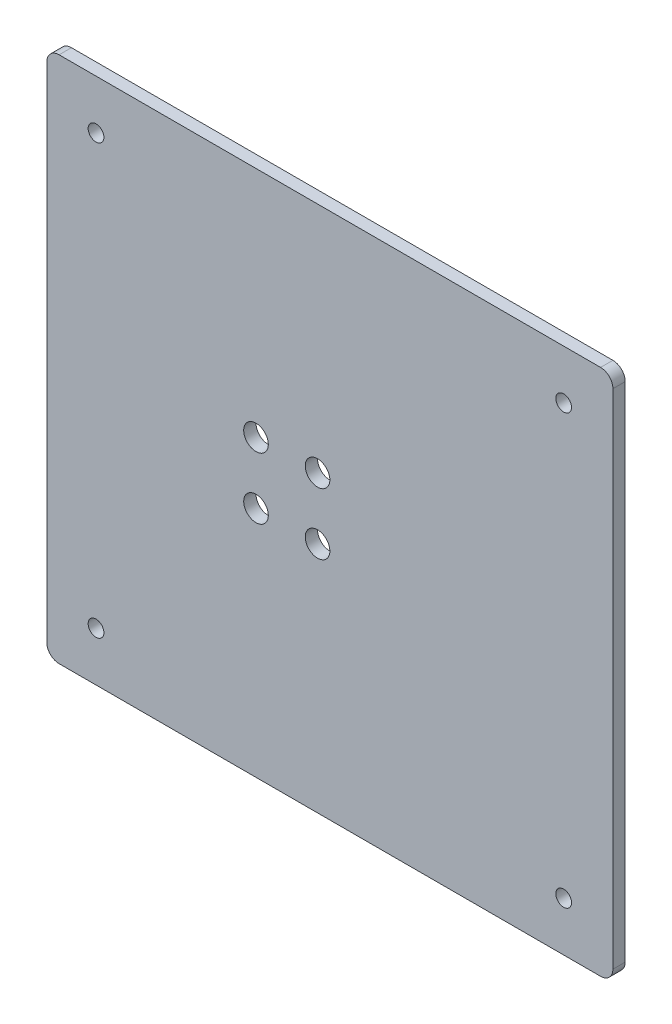
from build123d import *

# Parameters (mm, degrees)
SKETCH_1_W                  = 170
SKETCH_1_H                  = 154.25
SKETCH_1_W_2                = 160
SKETCH_1_H_2                = 144.25
EXTRUDE_1_DEPTH             = 8
FILLET_1_R                  = 5
SKETCH_2_W                  = 230
SKETCH_2_H                  = 214.25
EXTRUDE_2_DEPTH             = 5
FILLET_2_R                  = 5
HOLE_WIZARD_6_4_6_4_1_D     = 6.4
HOLE_WIZARD_6_4_6_4_1_DEPTH = 5
HOLE_WIZARD_10_0_10_1_D     = 10


with BuildPart() as part:
    # 草图1 → 凸台-拉伸1 (new body)
    with BuildSketch(Plane.XY):
        Rectangle(SKETCH_1_W, SKETCH_1_H)
        Rectangle(SKETCH_1_W_2, SKETCH_1_H_2, mode=Mode.SUBTRACT)
    extrude(amount=EXTRUDE_1_DEPTH)

    # 圆角1
    fillet_1_edges = [part.edges().sort_by_distance(p)[0] for p in [
        (-80, 72.125, 4),
        (-80, -72.125, 4),
        (80, -72.125, 4),
        (80, 72.125, 4),
        (-85, 77.125, 4),
        (85, 77.125, 4),
        (85, -77.125, 4),
        (-85, -77.125, 4),
    ]]
    fillet(fillet_1_edges, radius=FILLET_1_R)

    # 草图2 → 凸台-拉伸2 (add)
    with BuildSketch(Plane.XY.offset(8)):
        Rectangle(SKETCH_2_W, SKETCH_2_H)
    extrude(amount=EXTRUDE_2_DEPTH)

    # 圆角2
    fillet_2_edges = [part.edges().sort_by_distance(p)[0] for p in [
        (-115, 107.125, 10.5),
        (-115, -107.125, 10.5),
        (115, -107.125, 10.5),
        (115, 107.125, 10.5),
    ]]
    fillet(fillet_2_edges, radius=FILLET_2_R)

    # Ø6.4 (6.4) 直径孔1
    with Locations(Plane.XY.offset(13)):
        with Locations((-95, 87.125), (95, 87.125), (95, -87.125), (-95, -87.125)):
            Hole(HOLE_WIZARD_6_4_6_4_1_D / 2, depth=HOLE_WIZARD_6_4_6_4_1_DEPTH)

    # Ø10.0 (10) 直径孔1 (through all)
    with Locations(Plane.XY.offset(13)):
        with Locations((-30, 12.5), (-5, 12.5), (-5, -12.5), (-30, -12.5)):
            Hole(HOLE_WIZARD_10_0_10_1_D / 2)


solid = part.part
